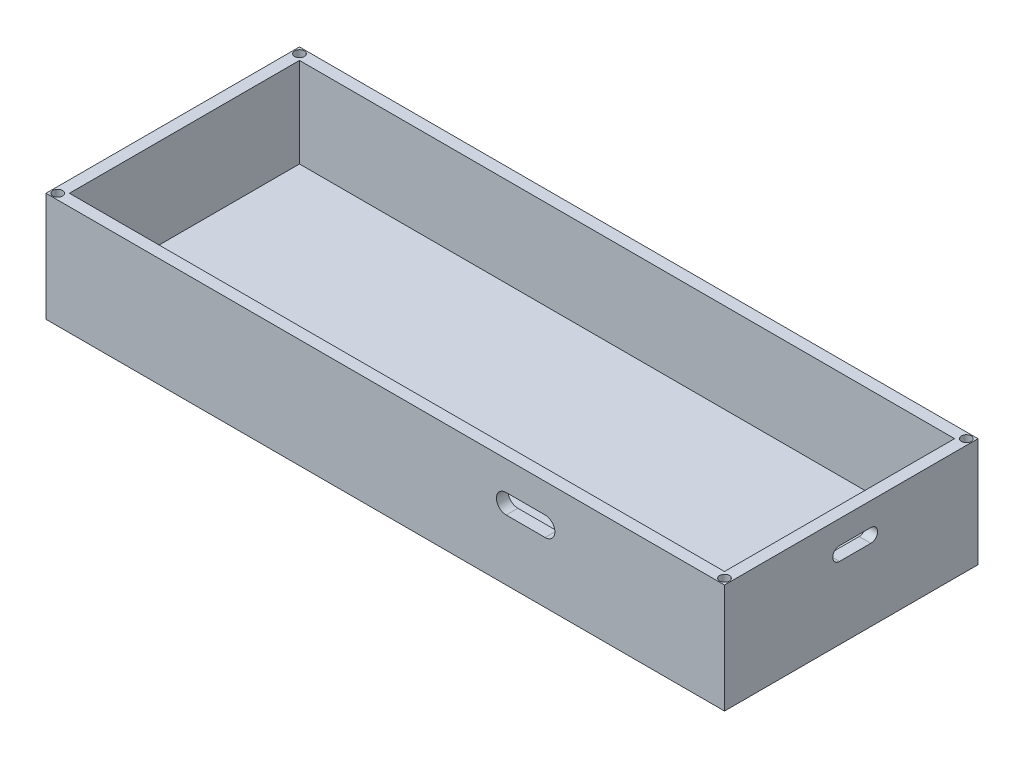
from build123d import *

# Parameters (mm, degrees)
SKETCH1_W            = 174
SKETCH1_H            = 65
BOSS_EXTRUDE1_DEPTH  = 5
SKETCH2_W            = 174
SKETCH2_H            = 65
SKETCH2_W_2          = 168
SKETCH2_H_2          = 59
BOSS_EXTRUDE2_DEPTH  = 23
CUT_EXTRUDE2_DEPTH   = 23
SKETCH4_R            = 1.25
CUT_EXTRUDE3_DEPTH   = 4
LPATTERN2_COUNT      = 2
LPATTERN2_PITCH      = 62
LPATTERN2_COUNT_DIR2 = 2
LPATTERN2_PITCH_DIR2 = 171
CUT_EXTRUDE4_DEPTH   = 10


with BuildPart() as part:
    # Sketch1 → Boss-Extrude1 (new body)
    with BuildSketch(Plane(origin=(0, 0, 0), x_dir=(1, 0, 0), z_dir=(0, 1, 0))):
        with Locations((87, 32.5)):
            Rectangle(SKETCH1_W, SKETCH1_H)
    extrude(amount=BOSS_EXTRUDE1_DEPTH)

    # Sketch2 → Boss-Extrude2 (add)
    with BuildSketch(Plane(origin=(0, 5, 0), x_dir=(1, 0, 0), z_dir=(0, 1, 0))):
        with Locations((87, 32.5)):
            Rectangle(SKETCH2_W, SKETCH2_H)
        with Locations((87, 32.5)):
            Rectangle(SKETCH2_W_2, SKETCH2_H_2, mode=Mode.SUBTRACT)
    extrude(amount=BOSS_EXTRUDE2_DEPTH)

    # Sketch3 → Cut-Extrude2 (cut)
    with BuildSketch(Plane(origin=(174, 0, 0), x_dir=(0, 0, -1), z_dir=(1, 0, 0))):
        with BuildLine():
            Line((29.5, 22), (37.5, 22))
            ThreePointArc((37.5, 22), (39.25, 20.25), (37.5, 18.5))
            Line((37.5, 18.5), (29.5, 18.5))
            ThreePointArc((29.5, 18.5), (27.75, 20.25), (29.5, 22))
        make_face()
    extrude(amount=-CUT_EXTRUDE2_DEPTH, mode=Mode.SUBTRACT)

    # Sketch4 → Cut-Extrude3 (cut)
    with BuildSketch(Plane(origin=(0, 28, 0), x_dir=(1, 0, 0), z_dir=(0, 1, 0))):
        with Locations((1.5, 1.5)):
            Circle(SKETCH4_R)
    cut_extrude3 = extrude(amount=-CUT_EXTRUDE3_DEPTH, mode=Mode.SUBTRACT)

    # LPattern2: Cut-Extrude3 2 × 2
    with Locations(*[(j * LPATTERN2_PITCH_DIR2, 0, -i * LPATTERN2_PITCH) for i in range(LPATTERN2_COUNT) for j in range(LPATTERN2_COUNT_DIR2) if (i, j) != (0, 0)]):
        add(cut_extrude3, mode=Mode.SUBTRACT)

    # Sketch5 → Cut-Extrude4 (cut)
    with BuildSketch(Plane.XY):
        with BuildLine():
            Line((128, 15.55), (118, 15.55))
            ThreePointArc((118, 15.55), (115.5, 18.05), (118, 20.55))
            Line((118, 20.55), (128, 20.55))
            ThreePointArc((128, 20.55), (130.5, 18.05), (128, 15.55))
        make_face()
    extrude(amount=-CUT_EXTRUDE4_DEPTH, mode=Mode.SUBTRACT)


solid = part.part
